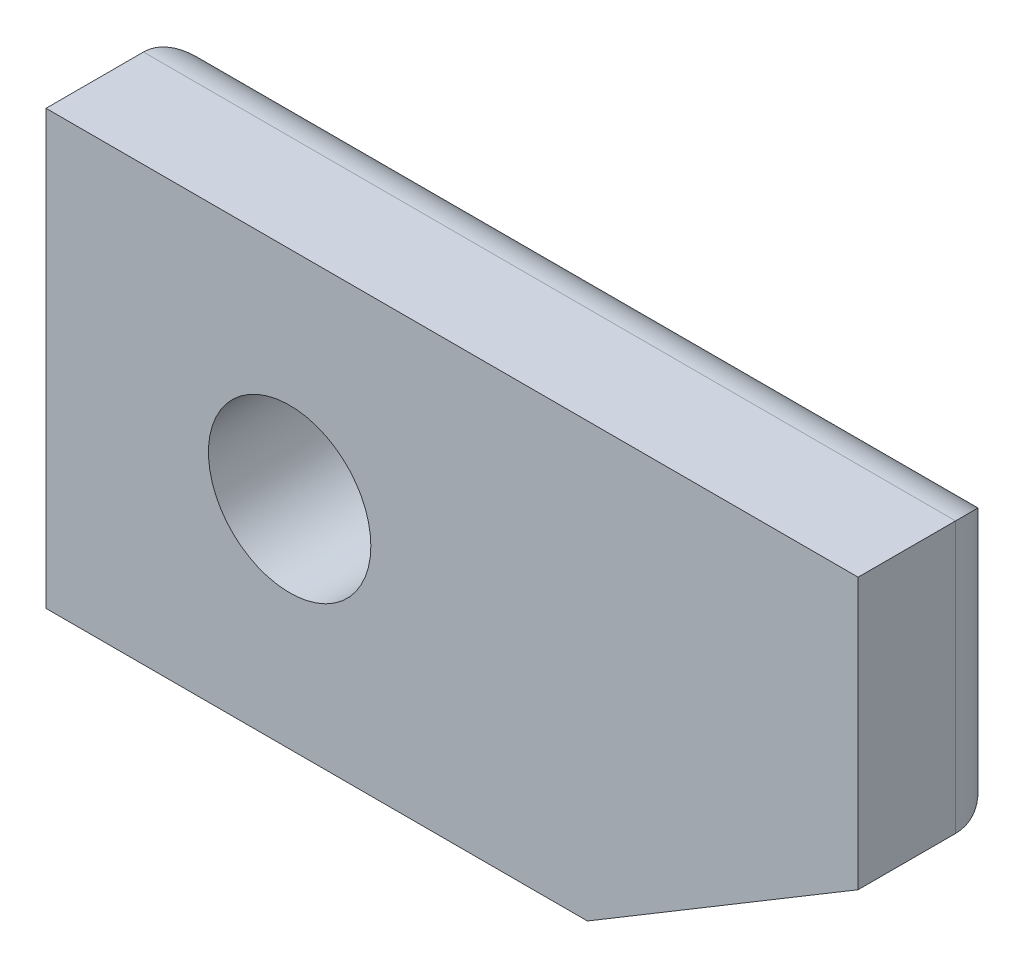
from build123d import *

# Parameters (mm, degrees)
SKETCH1_R           = 0.75
BOSS_EXTRUDE1_DEPTH = 1.4
FILLET1_R           = 0.5


with BuildPart() as part:
    # Sketch1 → Boss-Extrude1 (new body)
    with BuildSketch(Plane.XY):
        Polygon((-2.25, 2), (-2.25, -2), (2.75, -2), (5.25, -0.5), (5.25, 2), align=None)
        Circle(SKETCH1_R, mode=Mode.SUBTRACT)
    extrude(amount=BOSS_EXTRUDE1_DEPTH)

    # Fillet1
    fillet1_edges = [part.edges().sort_by_distance(p)[0] for p in [
        (5.25, 0.75, 0),
        (4, -1.25, 0),
        (0.25, -2, 0),
        (-2.25, 0, 0),
        (1.5, 2, 0),
    ]]
    fillet(fillet1_edges, radius=FILLET1_R)


solid = part.part
